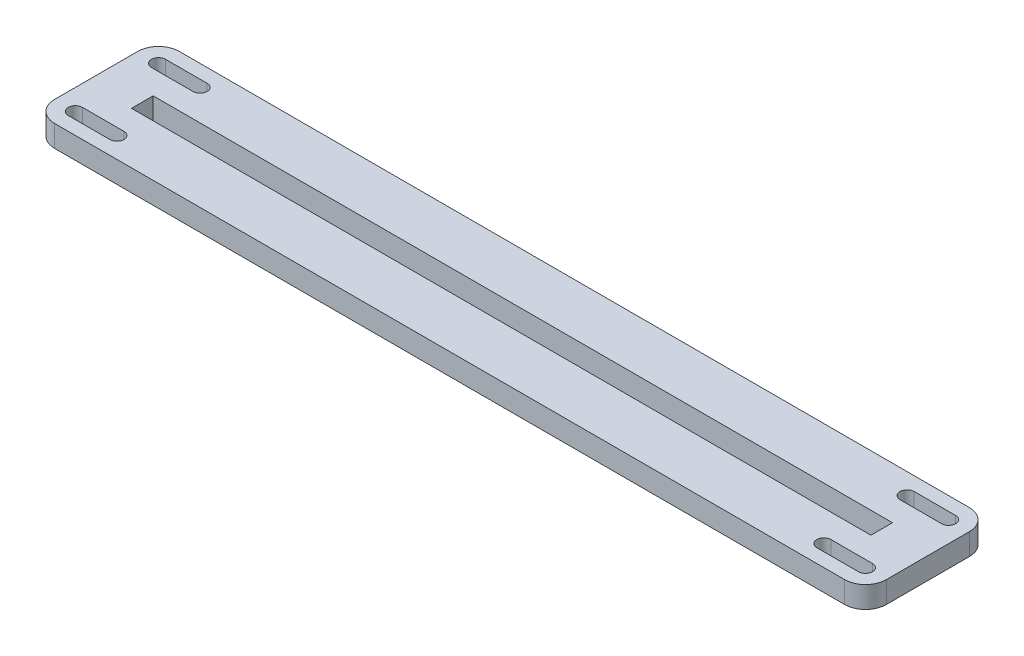
from build123d import *

# Parameters (mm, degrees)
SKETCH1_W           = 254
SKETCH1_H           = 38.1
SKETCH1_W_2         = 225.806
SKETCH1_H_2         = 6.604
BOSS_EXTRUDE1_DEPTH = 6.604
CUT_EXTRUDE1_DEPTH  = 7.604
FILLET1_R           = 6.35


with BuildPart() as part:
    # Sketch1 → Boss-Extrude1 (new body)
    with BuildSketch(Plane(origin=(0, 0, 0), x_dir=(1, 0, 0), z_dir=(0, 1, 0))):
        Rectangle(SKETCH1_W, SKETCH1_H)
        Rectangle(SKETCH1_W_2, SKETCH1_H_2, mode=Mode.SUBTRACT)
    extrude(amount=BOSS_EXTRUDE1_DEPTH)

    # Sketch2 → Cut-Extrude1 (cut, through all)
    with BuildSketch(Plane(origin=(0, 6.604, 0), x_dir=(1, 0, 0), z_dir=(0, 1, 0))):
        with BuildLine():
            Line((-120.65, 14.859), (-107.95, 14.859))
            ThreePointArc((-107.95, 14.859), (-105.791, 12.7), (-107.95, 10.541))
            Line((-107.95, 10.541), (-120.65, 10.541))
            ThreePointArc((-120.65, 10.541), (-122.809, 12.7), (-120.65, 14.859))
        make_face()
        with BuildLine():
            Line((-120.65, -10.541), (-107.95, -10.541))
            ThreePointArc((-107.95, -10.541), (-105.791, -12.7), (-107.95, -14.859))
            Line((-107.95, -14.859), (-120.65, -14.859))
            ThreePointArc((-120.65, -14.859), (-122.809, -12.7), (-120.65, -10.541))
        make_face()
    cut_extrude1 = extrude(amount=-CUT_EXTRUDE1_DEPTH, mode=Mode.SUBTRACT)

    # Mirror1: Cut-Extrude1 across plane
    add(cut_extrude1.mirror(Plane(origin=(0, 0, 0), x_dir=(0, 0, 1), z_dir=(1, 0, 0))), mode=Mode.SUBTRACT)

    # Fillet1
    fillet1_edges = [part.edges().sort_by_distance(p)[0] for p in [
        (-127, 3.302, -19.05),
        (127, 3.302, -19.05),
        (127, 3.302, 19.05),
        (-127, 3.302, 19.05),
    ]]
    fillet(fillet1_edges, radius=FILLET1_R)


solid = part.part
